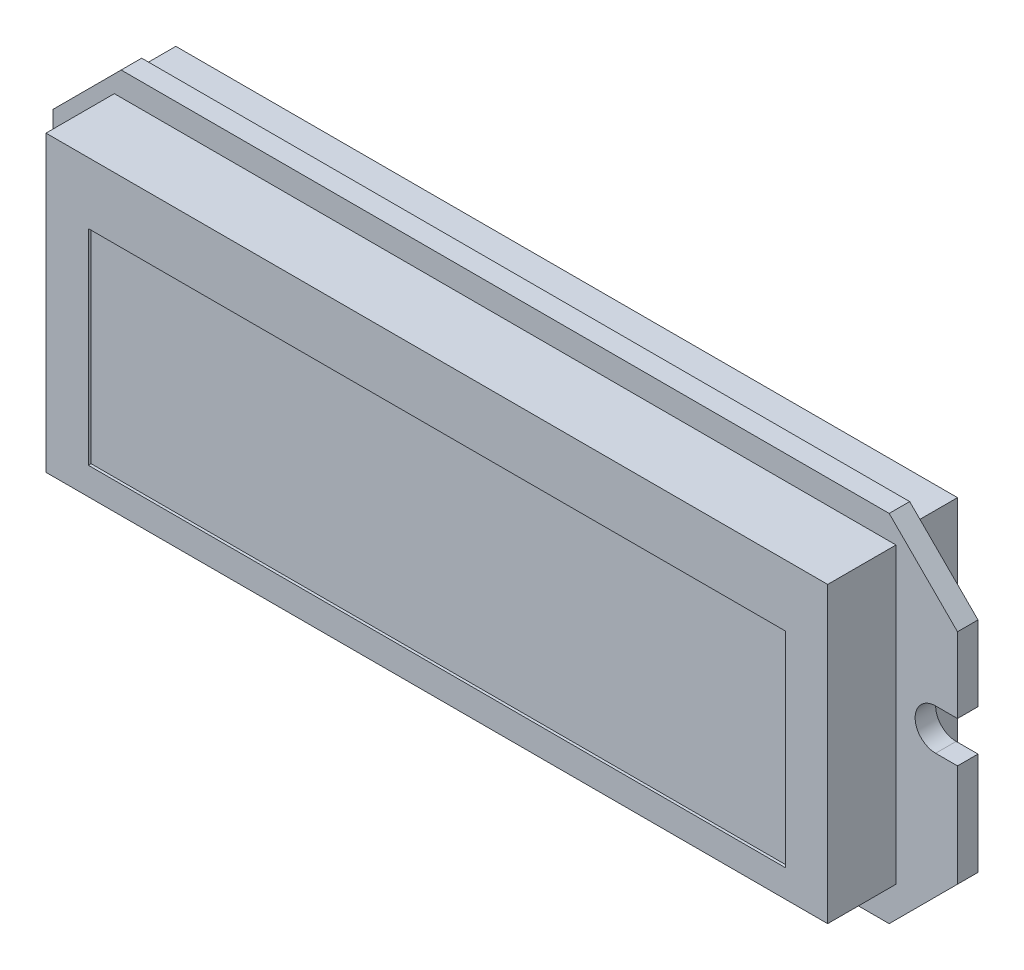
from build123d import *

# Parameters (mm, degrees)
SKETCH_1_W           = 66.2
SKETCH_1_H           = 26
EXTRUDE_1_DEPTH      = 1.5
SKETCH_3_W           = 57.2
SKETCH_3_H           = 21.5
EXTRUDE_2_DEPTH      = 5
CHAMFER_1_SIZE       = 5
CUT_EXTRUDE_1_DEPTH  = 7.5
SKETCH_6_W           = 51
SKETCH_6_H           = 15
CUT_EXTRUDE_2_DEPTH  = 0.2
EXTRUDE_3_DEPTH      = 0.05
EXTRUDE_3_DEPTH_BACK = 1.6
SKETCH_9_W           = 57.2
SKETCH_9_H           = 22
EXTRUDE_4_DEPTH      = 3


with BuildPart() as part:
    # Эскиз1 → Бобышка-Вытянуть1 (new body)
    with BuildSketch(Plane.XY):
        Rectangle(SKETCH_1_W, SKETCH_1_H)
    extrude(amount=-EXTRUDE_1_DEPTH)

    # Эскиз3 → Бобышка-Вытянуть2 (add)
    with BuildSketch(Plane.XY):
        with Locations((0, 0.5)):
            Rectangle(SKETCH_3_W, SKETCH_3_H)
    extrude(amount=EXTRUDE_2_DEPTH)

    # Фаска1
    chamfer_1_edges = [part.edges().sort_by_distance(p)[0] for p in [
        (-33.1, 13, -0.75),
        (33.1, 13, -0.75),
        (33.1, -13, -0.75),
        (-33.1, -13, -0.75),
    ]]
    chamfer(chamfer_1_edges, length=CHAMFER_1_SIZE)

    # Эскиз5 → Вырез-Вытянуть1 (cut, through all)
    with BuildSketch(Plane(origin=(0, 0, -1.5), x_dir=(-1, 0, 0), z_dir=(0, 0, -1))):
        with BuildLine():
            Line((-33.1, 2.5), (-31.5, 2.5))
            ThreePointArc((-31.5, 2.5), (-30, 1), (-31.5, -0.5))
            Line((-31.5, -0.5), (-34.1, -0.5))
            Line((-34.1, -0.5), (-34.1, 2.5))
            Line((-34.1, 2.5), (-33.1, 2.5))
        make_face()
        with BuildLine():
            Line((34.1, 2.5), (33.1, 2.5))
            Line((33.1, 2.5), (31.5, 2.5))
            ThreePointArc((31.5, 2.5), (30, 1), (31.5, -0.5))
            Line((31.5, -0.5), (34.1, -0.5))
            Line((34.1, -0.5), (34.1, 2.5))
        make_face()
    extrude(amount=-CUT_EXTRUDE_1_DEPTH, mode=Mode.SUBTRACT)

    # Эскиз6 → Вырез-Вытянуть2 (cut)
    with BuildSketch(Plane.XY.offset(5)):
        with Locations((0, -0.75)):
            Rectangle(SKETCH_6_W, SKETCH_6_H)
    extrude(amount=-CUT_EXTRUDE_2_DEPTH, mode=Mode.SUBTRACT)

    # Эскиз7 → Бобышка-Вытянуть3 (add, two sides)
    with BuildSketch(Plane.XY) as extrude_3_sk:
        with BuildLine():
            Line((25.4, -13), (24.6, -13))
            Line((24.6, -13), (24.6, -11.85))
            ThreePointArc((24.6, -11.85), (24.702512627, -11.602512627), (24.95, -11.5))
            Line((24.95, -11.5), (25.05, -11.5))
            ThreePointArc((25.05, -11.5), (25.297487373, -11.602512627), (25.4, -11.85))
            Line((25.4, -11.85), (25.4, -13))
        make_face()
        with BuildLine():
            Line((24.13, -13), (23.33, -13))
            Line((23.33, -13), (23.33, -11.85))
            ThreePointArc((23.33, -11.85), (23.432512627, -11.602512627), (23.68, -11.5))
            Line((23.68, -11.5), (23.78, -11.5))
            ThreePointArc((23.78, -11.5), (24.027487373, -11.602512627), (24.13, -11.85))
            Line((24.13, -11.85), (24.13, -13))
        make_face()
        with BuildLine():
            Line((22.86, -13), (22.06, -13))
            Line((22.06, -13), (22.06, -11.85))
            ThreePointArc((22.06, -11.85), (22.162512627, -11.602512627), (22.41, -11.5))
            Line((22.41, -11.5), (22.51, -11.5))
            ThreePointArc((22.51, -11.5), (22.757487373, -11.602512627), (22.86, -11.85))
            Line((22.86, -11.85), (22.86, -13))
        make_face()
        with BuildLine():
            Line((21.59, -13), (20.79, -13))
            Line((20.79, -13), (20.79, -11.85))
            ThreePointArc((20.79, -11.85), (20.892512627, -11.602512627), (21.14, -11.5))
            Line((21.14, -11.5), (21.24, -11.5))
            ThreePointArc((21.24, -11.5), (21.487487373, -11.602512627), (21.59, -11.85))
            Line((21.59, -11.85), (21.59, -13))
        make_face()
        with BuildLine():
            Line((20.32, -13), (19.52, -13))
            Line((19.52, -13), (19.52, -11.85))
            ThreePointArc((19.52, -11.85), (19.622512627, -11.602512627), (19.87, -11.5))
            Line((19.87, -11.5), (19.97, -11.5))
            ThreePointArc((19.97, -11.5), (20.217487373, -11.602512627), (20.32, -11.85))
            Line((20.32, -11.85), (20.32, -13))
        make_face()
        with BuildLine():
            Line((19.05, -13), (18.25, -13))
            Line((18.25, -13), (18.25, -11.85))
            ThreePointArc((18.25, -11.85), (18.352512627, -11.602512627), (18.6, -11.5))
            Line((18.6, -11.5), (18.7, -11.5))
            ThreePointArc((18.7, -11.5), (18.947487373, -11.602512627), (19.05, -11.85))
            Line((19.05, -11.85), (19.05, -13))
        make_face()
        with BuildLine():
            Line((17.78, -13), (16.98, -13))
            Line((16.98, -13), (16.98, -11.85))
            ThreePointArc((16.98, -11.85), (17.082512627, -11.602512627), (17.33, -11.5))
            Line((17.33, -11.5), (17.43, -11.5))
            ThreePointArc((17.43, -11.5), (17.677487373, -11.602512627), (17.78, -11.85))
            Line((17.78, -11.85), (17.78, -13))
        make_face()
        with BuildLine():
            Line((16.51, -13), (15.71, -13))
            Line((15.71, -13), (15.71, -11.85))
            ThreePointArc((15.71, -11.85), (15.812512627, -11.602512627), (16.06, -11.5))
            Line((16.06, -11.5), (16.16, -11.5))
            ThreePointArc((16.16, -11.5), (16.407487373, -11.602512627), (16.51, -11.85))
            Line((16.51, -11.85), (16.51, -13))
        make_face()
        with BuildLine():
            Line((15.24, -13), (14.44, -13))
            Line((14.44, -13), (14.44, -11.85))
            ThreePointArc((14.44, -11.85), (14.542512627, -11.602512627), (14.79, -11.5))
            Line((14.79, -11.5), (14.89, -11.5))
            ThreePointArc((14.89, -11.5), (15.137487373, -11.602512627), (15.24, -11.85))
            Line((15.24, -11.85), (15.24, -13))
        make_face()
        with BuildLine():
            Line((13.97, -13), (13.17, -13))
            Line((13.17, -13), (13.17, -11.85))
            ThreePointArc((13.17, -11.85), (13.272512627, -11.602512627), (13.52, -11.5))
            Line((13.52, -11.5), (13.62, -11.5))
            ThreePointArc((13.62, -11.5), (13.867487373, -11.602512627), (13.97, -11.85))
            Line((13.97, -11.85), (13.97, -13))
        make_face()
        with BuildLine():
            Line((12.7, -13), (11.9, -13))
            Line((11.9, -13), (11.9, -11.85))
            ThreePointArc((11.9, -11.85), (12.002512627, -11.602512627), (12.25, -11.5))
            Line((12.25, -11.5), (12.35, -11.5))
            ThreePointArc((12.35, -11.5), (12.597487373, -11.602512627), (12.7, -11.85))
            Line((12.7, -11.85), (12.7, -13))
        make_face()
        with BuildLine():
            Line((11.43, -13), (10.63, -13))
            Line((10.63, -13), (10.63, -11.85))
            ThreePointArc((10.63, -11.85), (10.732512627, -11.602512627), (10.98, -11.5))
            Line((10.98, -11.5), (11.08, -11.5))
            ThreePointArc((11.08, -11.5), (11.327487373, -11.602512627), (11.43, -11.85))
            Line((11.43, -11.85), (11.43, -13))
        make_face()
        with BuildLine():
            Line((10.16, -13), (9.36, -13))
            Line((9.36, -13), (9.36, -11.85))
            ThreePointArc((9.36, -11.85), (9.462512627, -11.602512627), (9.71, -11.5))
            Line((9.71, -11.5), (9.81, -11.5))
            ThreePointArc((9.81, -11.5), (10.057487373, -11.602512627), (10.16, -11.85))
            Line((10.16, -11.85), (10.16, -13))
        make_face()
        with BuildLine():
            Line((8.89, -13), (8.09, -13))
            Line((8.09, -13), (8.09, -11.85))
            ThreePointArc((8.09, -11.85), (8.192512627, -11.602512627), (8.44, -11.5))
            Line((8.44, -11.5), (8.54, -11.5))
            ThreePointArc((8.54, -11.5), (8.787487373, -11.602512627), (8.89, -11.85))
            Line((8.89, -11.85), (8.89, -13))
        make_face()
    extrude(amount=EXTRUDE_3_DEPTH)
    extrude(extrude_3_sk.sketch, amount=-EXTRUDE_3_DEPTH_BACK)

    # Эскиз9 → Бобышка-Вытянуть4 (add)
    with BuildSketch(Plane(origin=(0, 0, -1.5), x_dir=(-1, 0, 0), z_dir=(0, 0, -1))):
        with Locations((0, 1)):
            Rectangle(SKETCH_9_W, SKETCH_9_H)
    extrude(amount=EXTRUDE_4_DEPTH)


solid = part.part
